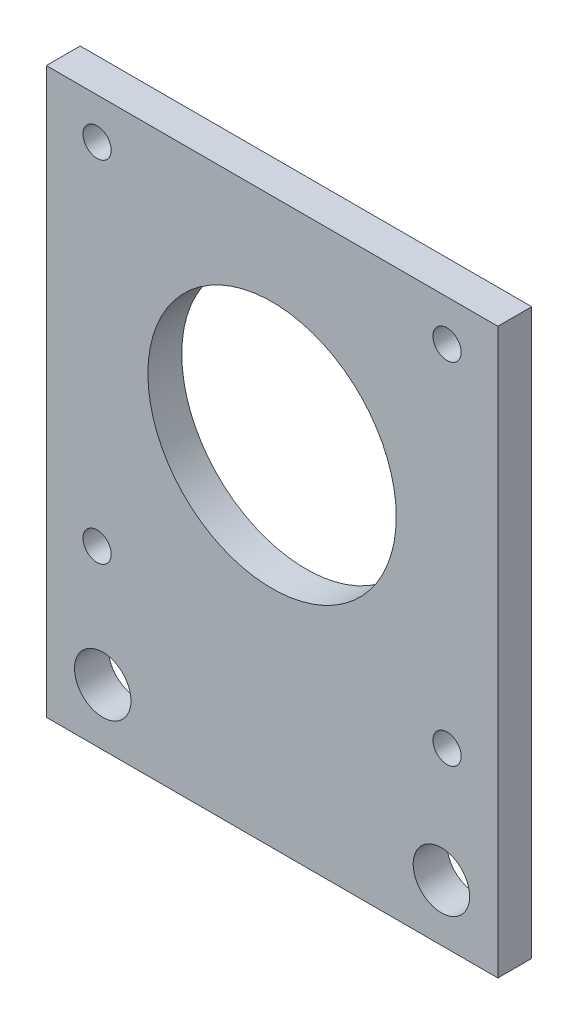
from build123d import *

# Parameters (mm, degrees)
SKETCH1_W           = 40
SKETCH1_H           = 50
SKETCH1_R           = 1.25
SKETCH1_R_2         = 2.5
SKETCH1_R_3         = 11
BOSS_EXTRUDE1_DEPTH = 3


with BuildPart() as part:
    # Sketch1 → Boss-Extrude1 (new body)
    with BuildSketch(Plane.XY):
        Rectangle(SKETCH1_W, SKETCH1_H)
        with Locations((-15.5, 21.375976324)):
            Circle(SKETCH1_R, mode=Mode.SUBTRACT)
        with Locations((-15.5, -9.624023676)):
            Circle(SKETCH1_R, mode=Mode.SUBTRACT)
        with Locations((15.5, 21.375976324)):
            Circle(SKETCH1_R, mode=Mode.SUBTRACT)
        with Locations((15.5, -9.624023676)):
            Circle(SKETCH1_R, mode=Mode.SUBTRACT)
        with Locations((-15, -20)):
            Circle(SKETCH1_R_2, mode=Mode.SUBTRACT)
        with Locations((15, -20)):
            Circle(SKETCH1_R_2, mode=Mode.SUBTRACT)
        with Locations((0, 5.875976324)):
            Circle(SKETCH1_R_3, mode=Mode.SUBTRACT)
    extrude(amount=BOSS_EXTRUDE1_DEPTH)


solid = part.part
